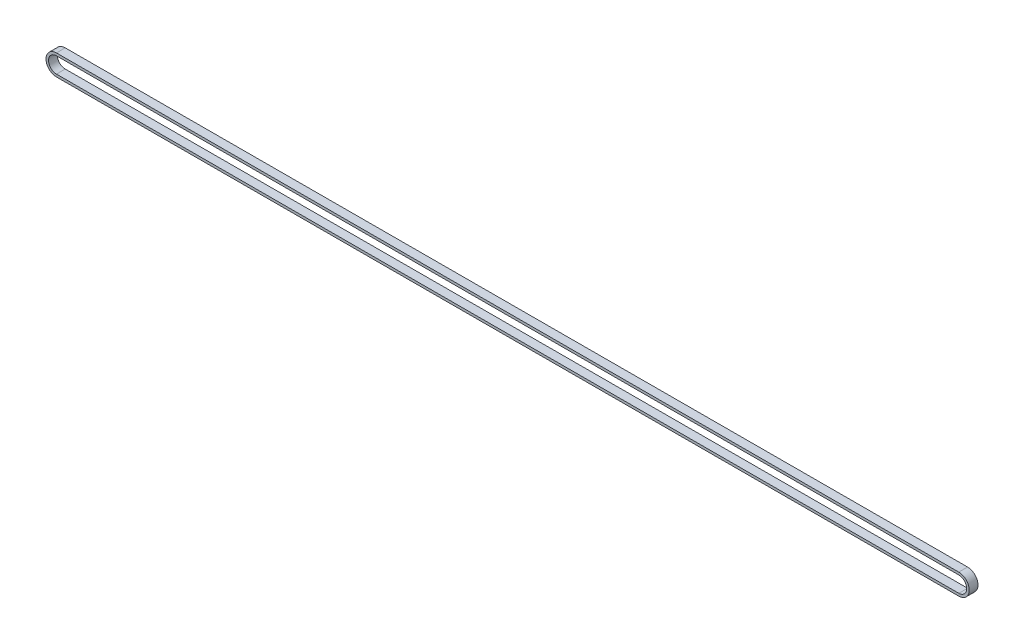
from build123d import *

# Parameters (mm, degrees)
EXTRUDE_1_DEPTH = 3.5


with BuildPart() as part:
    # 草图2 → 拉伸-薄壁1 (new, symmetric)
    with BuildSketch(Plane.XY):
        with BuildLine():
            Line((719.014288265, -8.304987759), (0.015352385, -9.54198547))
            ThreePointArc((0.015352385, -9.54198547), (-8.303923594, -1.251286031), (-0.013224155, 7.067989948))
            Line((-0.013224155, 7.067989948), (718.985711725, 8.304987659))
            ThreePointArc((718.985711725, 8.304987659), (727.304987704, 0.01428822), (719.014288265, -8.304987759))
        make_face()
        with BuildLine():
            Line((719.010847381, -6.304990718), (0.011911501, -7.54198843))
            ThreePointArc((0.011911501, -7.54198843), (-6.303926554, -1.247845147), (-0.009783271, 5.067992908))
            Line((-0.009783271, 5.067992908), (718.989152609, 6.304990619))
            ThreePointArc((718.989152609, 6.304990619), (725.304990664, 0.010847336), (719.010847381, -6.304990718))
        make_face(mode=Mode.SUBTRACT)
    extrude(amount=EXTRUDE_1_DEPTH, both=True)


solid = part.part
